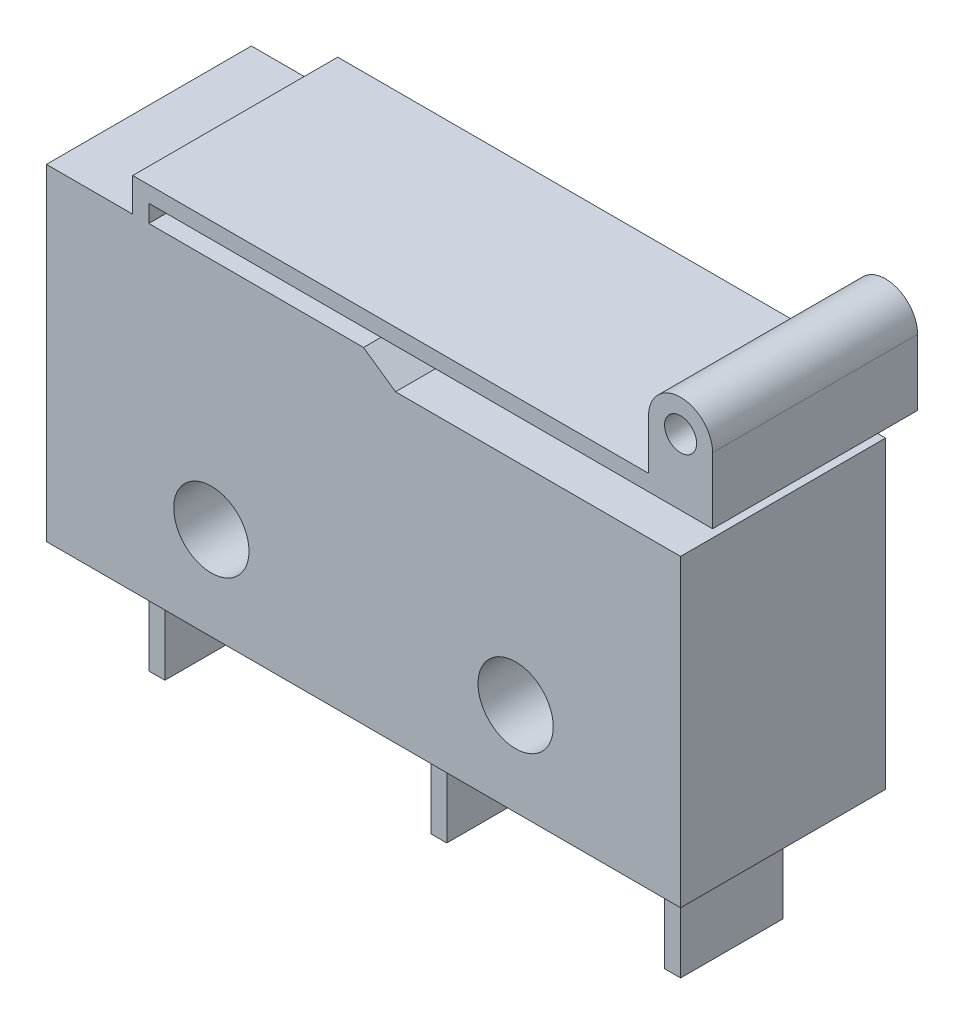
from build123d import *

# Parameters (mm, degrees)
SKETCH1_R           = 1.175
SKETCH1_R_2         = 0.5
BOSS_EXTRUDE1_DEPTH = 6.4
SKETCH2_W           = 1.6
SKETCH2_H           = 3.5
CUT_EXTRUDE1_DEPTH  = 21.8
CUT_EXTRUDE2_DEPTH  = 7.4


with BuildPart() as part:
    # Sketch1 → Boss-Extrude1 (new body)
    with BuildSketch(Plane.XY):
        with BuildLine():
            Line((2.1, 0), (10.4, 0))
            Line((10.4, 0), (10.4, -3.5))
            Line((10.4, -3.5), (10.9, -3.5))
            Line((10.9, -3.5), (10.9, 0))
            Line((10.9, 0), (17.7, 0))
            Line((17.7, 0), (17.7, -3.5))
            Line((17.7, -3.5), (18.2, -3.5))
            Line((18.2, -3.5), (18.2, 0))
            Line((18.2, 0), (19.8, 0))
            Line((19.8, 0), (19.8, 10.2))
            Line((19.8, 10.2), (3.195717589, 10.2))
            Line((3.195717589, 10.2), (3.195717589, 10.746282688))
            Line((3.195717589, 10.746282688), (20.8, 10.746282688))
            Line((20.8, 10.746282688), (20.8, 12.80322859))
            ThreePointArc((20.8, 12.80322859), (19.8, 13.80322859), (18.8, 12.80322859))
            Line((18.8, 12.80322859), (18.8, 11.246282688))
            Line((18.8, 11.246282688), (2.695717589, 11.246282688))
            Line((2.695717589, 11.246282688), (2.695717589, 10.2))
            Line((2.695717589, 10.2), (0, 10.2))
            Line((0, 10.2), (0, 0))
            Line((0, 0), (1.6, 0))
            Line((1.6, 0), (1.6, -3.5))
            Line((1.6, -3.5), (2.1, -3.5))
            Line((2.1, -3.5), (2.1, 0))
        make_face()
        with Locations((5.15, 2.9)):
            Circle(SKETCH1_R, mode=Mode.SUBTRACT)
        with Locations((14.65, 2.9)):
            Circle(SKETCH1_R, mode=Mode.SUBTRACT)
        with Locations((19.8, 12.80322859)):
            Circle(SKETCH1_R_2, mode=Mode.SUBTRACT)
    extrude(amount=BOSS_EXTRUDE1_DEPTH)

    # Sketch2 → Cut-Extrude1 (cut, through all)
    with BuildSketch(Plane.ZY):
        with Locations((0.8, -1.75)):
            Rectangle(SKETCH2_W, SKETCH2_H)
        with Locations((5.6, -1.75)):
            Rectangle(SKETCH2_W, SKETCH2_H)
    extrude(amount=-CUT_EXTRUDE1_DEPTH, mode=Mode.SUBTRACT)

    # Sketch3 → Cut-Extrude2 (cut, through all)
    with BuildSketch(Plane.XY.offset(6.4)):
        Polygon((19.8, 9.5), (10.9, 9.5), (9.9, 10.2), (19.8, 10.2), align=None)
    extrude(amount=-CUT_EXTRUDE2_DEPTH, mode=Mode.SUBTRACT)


solid = part.part
